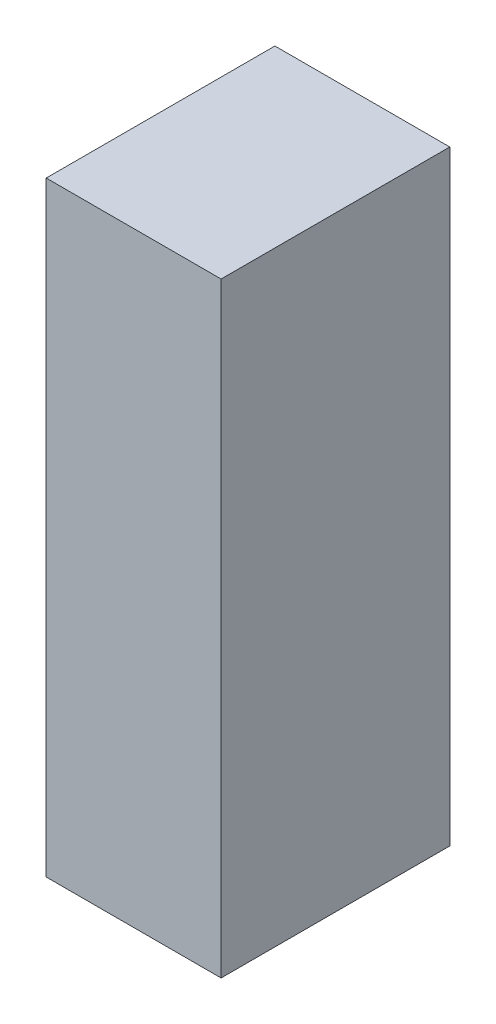
from build123d import *

# Parameters (mm, degrees)
SKETCH1_W           = 13
SKETCH1_H           = 17
BOSS_EXTRUDE1_DEPTH = 45


with BuildPart() as part:
    # Sketch1 → Boss-Extrude1 (new body)
    with BuildSketch(Plane(origin=(0, 0, 0), x_dir=(1, 0, 0), z_dir=(0, 1, 0))):
        Rectangle(SKETCH1_W, SKETCH1_H)
    extrude(amount=BOSS_EXTRUDE1_DEPTH)


solid = part.part
